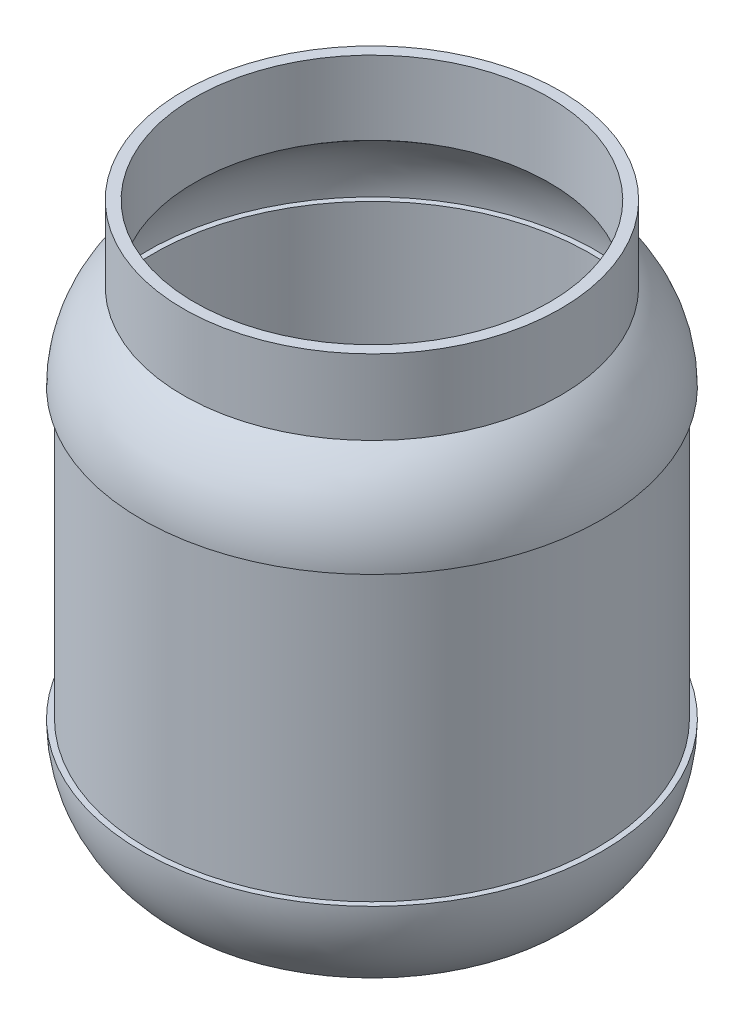
from build123d import *


with BuildPart() as part:
    # Sketch1 → Revolve1 (revolve)
    with BuildSketch(Plane.XY):
        with BuildLine():
            Line((0, 1.5875), (0, 0))
            Line((0, 0), (12.7, 0))
            Line((12.7, 0), (14.732, -2.116666667))
            Line((14.732, -2.116666667), (25.146, -2.116666667))
            Line((25.146, -2.116666667), (27.178, -4.233333333))
            Line((27.178, -4.233333333), (48.768, -4.233333333))
            Line((48.768, -4.233333333), (50.8, -6.35))
            Line((50.8, -6.35), (53.975, -6.35))
            ThreePointArc((53.975, -6.35), (62.187816399, 5.1877522), (65.0875, 19.05))
            Line((65.0875, 19.05), (63.5, 19.05))
            Line((63.5, 19.05), (63.5, 100.33))
            Line((63.5, 100.33), (65.0875, 100.33))
            ThreePointArc((65.0875, 100.33), (61.99894302, 113.920372302), (53.34, 124.841))
            Line((53.34, 124.841), (53.34, 146.05))
            Line((53.34, 146.05), (50.165, 146.05))
            Line((50.165, 146.05), (50.165, 125.199035015))
            ThreePointArc((50.165, 125.199035015), (50.967982729, 124.646456623), (51.7525, 124.067961338))
            ThreePointArc((51.7525, 124.067961338), (60.040796597, 114.279841026), (63.457766616, 101.9175))
            Line((63.457766616, 101.9175), (61.9125, 101.9175))
            Line((61.9125, 101.9175), (61.9125, 17.4625))
            Line((61.9125, 17.4625), (63.461790592, 17.4625))
            ThreePointArc((63.461790592, 17.4625), (60.535122298, 5.379756942), (53.345359351, -4.7625))
            Line((53.345359351, -4.7625), (51.476620878, -4.7625))
            Line((51.476620878, -4.7625), (49.444620878, -2.645833333))
            Line((49.444620878, -2.645833333), (27.854620878, -2.645833333))
            Line((27.854620878, -2.645833333), (25.822620878, -0.529166667))
            Line((25.822620878, -0.529166667), (15.408620878, -0.529166667))
            Line((15.408620878, -0.529166667), (13.376620878, 1.5875))
            Line((13.376620878, 1.5875), (1.5875, 1.5875))
            Line((1.5875, 1.5875), (0, 1.5875))
        make_face()
    revolve(axis=Axis((0, 0, 0), (0, 1, 0)))


solid = part.part
